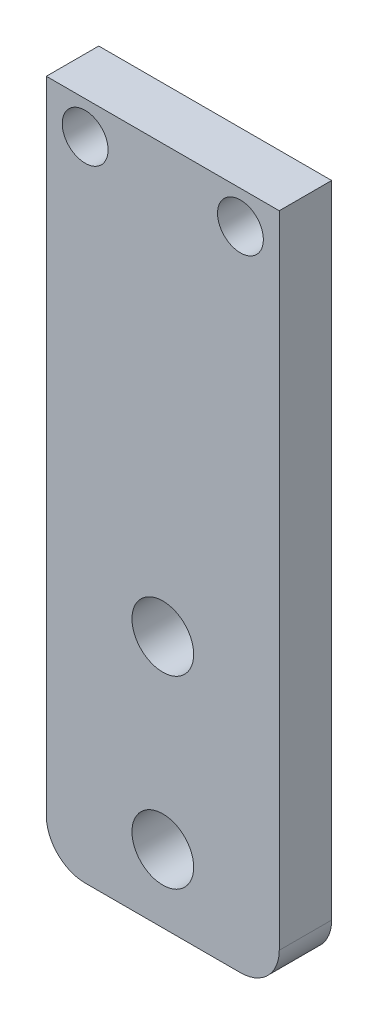
from build123d import *

# Parameters (mm, degrees)
SKETCH1_W           = 15.24
SKETCH1_H           = 44.45
SKETCH1_R           = 2.0193
SKETCH1_R_2         = 1.5
BOSS_EXTRUDE1_DEPTH = 3.429
FILLET1_R           = 2.54


with BuildPart() as part:
    # Sketch1 → Boss-Extrude1 (new body)
    with BuildSketch(Plane.XY):
        with Locations((0, 22.225)):
            Rectangle(SKETCH1_W, SKETCH1_H)
        with Locations((0, 4.445)):
            Circle(SKETCH1_R, mode=Mode.SUBTRACT)
        with Locations((0, 16.51)):
            Circle(SKETCH1_R, mode=Mode.SUBTRACT)
        with Locations((-5.08, 42.291)):
            Circle(SKETCH1_R_2, mode=Mode.SUBTRACT)
        with Locations((5.08, 42.291)):
            Circle(SKETCH1_R_2, mode=Mode.SUBTRACT)
    extrude(amount=BOSS_EXTRUDE1_DEPTH)

    # Fillet1
    fillet1_edges = [part.edges().sort_by_distance(p)[0] for p in [
        (7.62, 0, 1.7145),
        (-7.62, 0, 1.7145),
    ]]
    fillet(fillet1_edges, radius=FILLET1_R)


solid = part.part
